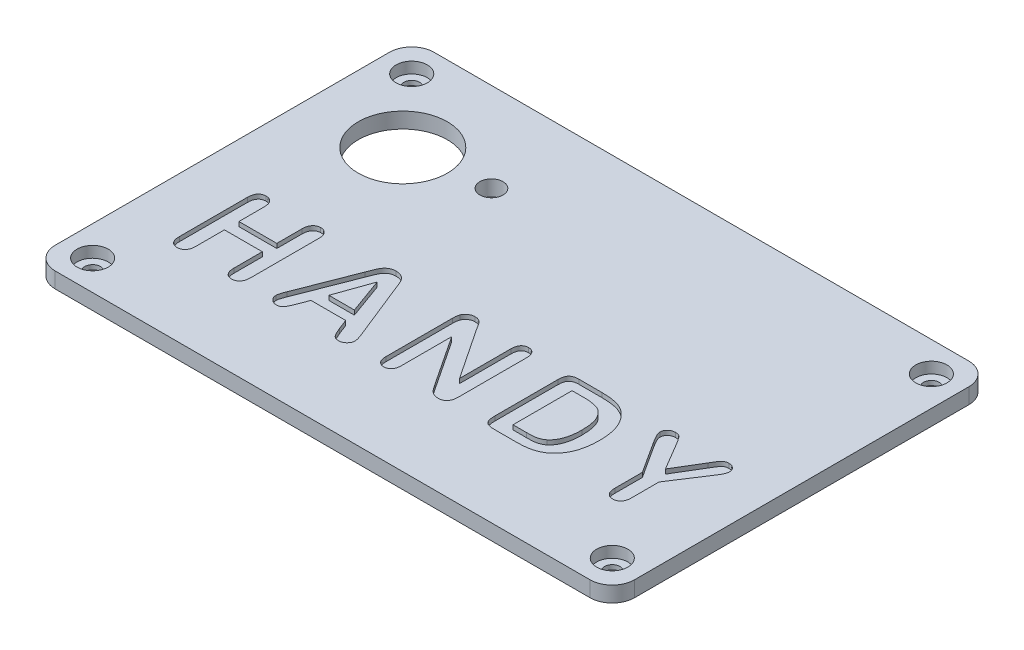
from build123d import *

# Parameters (mm, degrees)
SCHIZZO1_W                   = 130
SCHIZZO1_H                   = 85
ESTRUSIONE_ESTRUSIONE1_DEPTH = 3.5
RACCORDO1_R                  = 5
RACCORDO2_R                  = 5
RACCORDO3_R                  = 5
RACCORDO4_R                  = 5
SCHIZZO12_R                  = 10
TAGLIO_ESTRUSIONE2_DEPTH     = 3.5
SCHIZZO14_R                  = 2.6
TAGLIO_ESTRUSIONE3_DEPTH     = 3.5
TAGLIO_ESTRUSIONE9_DEPTH     = 1
SCHIZZO29_R                  = 1.75
TAGLIO_ESTRUSIONE10_DEPTH    = 3.5
SCHIZZO30_R                  = 3.5
TAGLIO_ESTRUSIONE11_DEPTH    = 2.5


with BuildPart() as part:
    # Schizzo1 → Estrusione-Estrusione1 (new body)
    with BuildSketch(Plane(origin=(0, 0, 0), x_dir=(1, 0, 0), z_dir=(0, 1, 0))):
        with Locations((65, 42.5)):
            Rectangle(SCHIZZO1_W, SCHIZZO1_H)
    extrude(amount=-ESTRUSIONE_ESTRUSIONE1_DEPTH)

    # Raccordo1
    raccordo1_edges = [part.edges().sort_by_distance(p)[0] for p in [
        (130, -1.75, 0),
    ]]
    fillet(raccordo1_edges, radius=RACCORDO1_R)

    # Raccordo2
    raccordo2_edges = [part.edges().sort_by_distance(p)[0] for p in [
        (130, -1.75, -85),
    ]]
    fillet(raccordo2_edges, radius=RACCORDO2_R)

    # Raccordo3
    raccordo3_edges = [part.edges().sort_by_distance(p)[0] for p in [
        (0, -1.75, -85),
    ]]
    fillet(raccordo3_edges, radius=RACCORDO3_R)

    # Raccordo4
    raccordo4_edges = [part.edges().sort_by_distance(p)[0] for p in [
        (0, -1.75, 0),
    ]]
    fillet(raccordo4_edges, radius=RACCORDO4_R)

    # Schizzo12 → Taglio-Estrusione2 (cut)
    with BuildSketch(Plane(origin=(0, 0, 0), x_dir=(1, 0, 0), z_dir=(0, 1, 0))):
        with Locations((20, 63)):
            Circle(SCHIZZO12_R)
    extrude(amount=-TAGLIO_ESTRUSIONE2_DEPTH, mode=Mode.SUBTRACT)

    # Schizzo14 → Taglio-Estrusione3 (cut)
    with BuildSketch(Plane(origin=(0, 0, 0), x_dir=(1, 0, 0), z_dir=(0, 1, 0))):
        with Locations((37.88854382, 65)):
            Circle(SCHIZZO14_R)
    extrude(amount=-TAGLIO_ESTRUSIONE3_DEPTH, mode=Mode.SUBTRACT)

    # Schizzo28 → Taglio-Estrusione9 (cut)
    with BuildSketch(Plane(origin=(0, 0, 0), x_dir=(1, 0, 0), z_dir=(0, 1, 0))):
        with BuildLine():
            Line((16, 35.829423521), (16, 30.227861021))
            Line((16, 30.227861021), (24.5, 30.227861021))
            Line((24.5, 30.227861021), (24.5, 35.829423521))
            add(Edge.make_bspline(
                [(24.5, 35.829423521), (24.504819175, 36.017416194), (24.513897939, 36.371572485), (24.611065343, 36.865238101), (24.769479801, 37.285985584), (24.994979646, 37.631146203), (25.278527591, 37.895342217), (25.599100815, 38.094603014), (25.967036773, 38.205160795), (26.223263113, 38.220134834), (26.35546875, 38.227861021)],
                knots=[0, 0, 0, 0, 0.000563367, 0.001061319, 0.001501635, 0.00190466, 0.002285995, 0.002655791, 0.003027707, 0.003424167, 0.003424167, 0.003424167, 0.003424167], degree=3))
            add(Edge.make_bspline(
                [(26.35546875, 38.227861021), (26.490542865, 38.222400532), (26.752884148, 38.211795157), (27.123820168, 38.091691153), (27.456477722, 37.906376855), (27.742311924, 37.641646055), (27.977193769, 37.303779609), (28.13964448, 36.885453798), (28.236139538, 36.393729531), (28.245182464, 36.040852835), (28.25, 35.852861021)],
                knots=[0, 0, 0, 0, 0.000403877, 0.00078441, 0.001157002, 0.001538537, 0.001942716, 0.002380843, 0.002874964, 0.003438332, 0.003438332, 0.003438332, 0.003438332], degree=3))
            Line((28.25, 35.852861021), (28.25, 20.614579771))
            add(Edge.make_bspline(
                [(28.25, 20.614579771), (28.245762205, 20.426462918), (28.237801584, 20.07308878), (28.133804062, 19.581462938), (27.973891929, 19.159089268), (27.735718866, 18.817428131), (27.444355306, 18.556757949), (27.118431825, 18.361575022), (26.747834988, 18.250386044), (26.489003393, 18.235526999), (26.35546875, 18.227861021)],
                knots=[0, 0, 0, 0, 0.000563367, 0.001058276, 0.001500027, 0.001909644, 0.002294067, 0.002665223, 0.003040873, 0.003441221, 0.003441221, 0.003441221, 0.003441221], degree=3))
            add(Edge.make_bspline(
                [(26.35546875, 18.227861021), (26.220311497, 18.233011963), (25.960302235, 18.242921106), (25.593818183, 18.365107708), (25.266599728, 18.548559267), (24.987209876, 18.813591642), (24.767299772, 19.154017113), (24.606190458, 19.564991003), (24.51530789, 20.04946092), (24.505314473, 20.395435279), (24.5, 20.579423521)],
                knots=[0, 0, 0, 0, 0.000403877, 0.000776959, 0.001146157, 0.00152197, 0.001919583, 0.002352631, 0.002838327, 0.003389994, 0.003389994, 0.003389994, 0.003389994], degree=3))
            Line((24.5, 20.579423521), (24.5, 26.977861021))
            Line((24.5, 26.977861021), (16, 26.977861021))
            Line((16, 26.977861021), (16, 20.579423521))
            add(Edge.make_bspline(
                [(16, 20.579423521), (15.995620095, 20.393939038), (15.987368634, 20.044498161), (15.884730284, 19.558859998), (15.722787066, 19.142357709), (15.485643023, 18.805492611), (15.194216223, 18.54836119), (14.867321444, 18.358589531), (14.498166265, 18.245306585), (14.239077497, 18.233796581), (14.10546875, 18.227861021)],
                knots=[0, 0, 0, 0, 0.000555567, 0.001046653, 0.001481161, 0.00188758, 0.002269394, 0.002638592, 0.003014242, 0.003414228, 0.003414228, 0.003414228, 0.003414228], degree=3))
            add(Edge.make_bspline(
                [(14.10546875, 18.227861021), (13.970525237, 18.23519005), (13.711427513, 18.249262122), (13.341980957, 18.363115869), (13.016489282, 18.553389644), (12.737201356, 18.821553811), (12.515263914, 19.167775393), (12.357906186, 19.586599094), (12.264714428, 20.077983215), (12.255118075, 20.42793701), (12.25, 20.614579771)],
                knots=[0, 0, 0, 0, 0.000404236, 0.000776151, 0.001147306, 0.00152581, 0.00192669, 0.002370647, 0.002860177, 0.003419644, 0.003419644, 0.003419644, 0.003419644], degree=3))
            Line((12.25, 20.614579771), (12.25, 35.852861021))
            add(Edge.make_bspline(
                [(12.25, 35.852861021), (12.254861535, 36.03961068), (12.263976876, 36.389764911), (12.359920335, 36.877721635), (12.505497685, 37.29786493), (12.731310913, 37.638071279), (13.006718206, 37.905942385), (13.335000733, 38.093312343), (13.705506461, 38.211940289), (13.969112261, 38.222433271), (14.10546875, 38.227861021)],
                knots=[0, 0, 0, 0, 0.000559467, 0.001048997, 0.001486532, 0.001884145, 0.002262648, 0.002628462, 0.003008996, 0.003416764, 0.003416764, 0.003416764, 0.003416764], degree=3))
            add(Edge.make_bspline(
                [(14.10546875, 38.227861021), (14.240555727, 38.222415396), (14.502921991, 38.211838891), (14.873680167, 38.091529357), (15.207775264, 37.906545548), (15.492282478, 37.637220489), (15.727229163, 37.29581373), (15.89021347, 36.872428327), (15.985724691, 36.375381758), (15.995051131, 36.018692698), (16, 35.829423521)],
                knots=[0, 0, 0, 0, 0.000403877, 0.00078441, 0.001157002, 0.001541187, 0.001948581, 0.002390333, 0.002892115, 0.003459383, 0.003459383, 0.003459383, 0.003459383], degree=3))
        make_face()
        with BuildLine():
            Line((48.11328125, 20.645829771), (47.19921875, 22.977861021))
            Line((47.19921875, 22.977861021), (39.421875, 22.977861021))
            Line((39.421875, 22.977861021), (38.5078125, 20.595048521))
            add(Edge.make_bspline(
                [(38.5078125, 20.595048521), (38.423880126, 20.380686838), (38.270045658, 19.987796539), (38.031609163, 19.460860576), (37.815483793, 19.045611246), (37.615071434, 18.723112851), (37.38130707, 18.485339378), (37.088182176, 18.333005971), (36.738340395, 18.24328834), (36.486278791, 18.233234418), (36.3515625, 18.227861021)],
                knots=[0, 0, 0, 0, 0.000690556, 0.001265678, 0.001733972, 0.002094745, 0.002401355, 0.002721214, 0.003072733, 0.003476289, 0.003476289, 0.003476289, 0.003476289], degree=3))
            add(Edge.make_bspline(
                [(36.3515625, 18.227861021), (36.232292304, 18.23458236), (35.997086222, 18.247837137), (35.657112775, 18.35543674), (35.339730265, 18.527029837), (35.051798307, 18.758969192), (34.808630848, 19.032860172), (34.632418345, 19.337365774), (34.519408043, 19.66016186), (34.506496599, 19.884508617), (34.5, 19.997392271)],
                knots=[0, 0, 0, 0, 0.000357203, 0.00070442, 0.001059201, 0.001434384, 0.0018081, 0.00215114, 0.002484661, 0.002822433, 0.002822433, 0.002822433, 0.002822433], degree=3))
            add(Edge.make_bspline(
                [(34.5, 19.997392271), (34.506021036, 20.132056724), (34.518389365, 20.408682609), (34.606367654, 20.757509051), (34.711996109, 21.059096915), (34.809592497, 21.332616659), (34.925514842, 21.648731366), (35.014979275, 21.871338033), (35.0625, 21.989579771)],
                knots=[0, 0, 0, 0, 0.000403556, 0.000828978, 0.001072329, 0.001362681, 0.001700092, 0.002082366, 0.002082366, 0.002082366, 0.002082366], degree=3))
            Line((35.0625, 21.989579771), (39.95703125, 34.548173521))
            add(Edge.make_bspline(
                [(39.95703125, 34.548173521), (39.993222724, 34.643329111), (40.068697286, 34.841768849), (40.192711767, 35.151331646), (40.318591306, 35.49025036), (40.457040416, 35.846035813), (40.597923576, 36.202370263), (40.75654517, 36.532490679), (40.909599004, 36.83556295), (41.075765981, 37.105428432), (41.256790067, 37.349102363), (41.464237199, 37.564323499), (41.699337666, 37.753177599), (41.956729117, 37.923893844), (42.24684487, 38.060834127), (42.568950603, 38.159011855), (42.922338043, 38.217641971), (43.169039081, 38.224373083), (43.296875, 38.227861021)],
                knots=[0, 0, 0, 0, 0.000305413, 0.000636915, 0.001000385, 0.001389935, 0.001782372, 0.002149331, 0.002488275, 0.002800482, 0.003098921, 0.003397283, 0.003694389, 0.004002091, 0.004321855, 0.004652989, 0.005009401, 0.005392712, 0.005392712, 0.005392712, 0.005392712], degree=3))
            add(Edge.make_bspline(
                [(43.296875, 38.227861021), (43.426028579, 38.224408528), (43.675347921, 38.217743802), (44.032358158, 38.158592175), (44.356896212, 38.062866669), (44.644448297, 37.922191818), (44.903689239, 37.756440943), (45.139591077, 37.570625171), (45.344786796, 37.355850612), (45.582491853, 37.040846266), (45.838224036, 36.613949879), (46.052176661, 36.153238269), (46.207312376, 35.747767817), (46.352416394, 35.400310434), (46.501661241, 35.001423448), (46.607989954, 34.720013053), (46.6640625, 34.571611021)],
                knots=[0, 0, 0, 0, 0.000387212, 0.000747477, 0.001082346, 0.001398583, 0.001704171, 0.002004317, 0.002297156, 0.002592485, 0.00318671, 0.003786112, 0.004113982, 0.004489002, 0.004915571, 0.005391509, 0.005391509, 0.005391509, 0.005391509], degree=3))
            Line((46.6640625, 34.571611021), (51.6640625, 22.095048521))
            add(Edge.make_bspline(
                [(51.6640625, 22.095048521), (51.709769372, 21.980533321), (51.797785114, 21.760016364), (51.922269913, 21.441666952), (52.01508165, 21.143075814), (52.107401459, 20.873893132), (52.166344257, 20.624468819), (52.215273245, 20.402385557), (52.245511947, 20.203967891), (52.248561909, 20.079512074), (52.25, 20.020829771)],
                knots=[0, 0, 0, 0, 0.000369941, 0.000712379, 0.001024903, 0.001307803, 0.001565497, 0.001793034, 0.001990251, 0.002166206, 0.002166206, 0.002166206, 0.002166206], degree=3))
            add(Edge.make_bspline(
                [(52.25, 20.020829771), (52.242816192, 19.910753739), (52.228398423, 19.689833194), (52.122771788, 19.365634001), (51.939387808, 19.06224382), (51.701786429, 18.777764097), (51.415890172, 18.53381929), (51.088694902, 18.35653975), (50.733475439, 18.247272147), (50.485143947, 18.234386853), (50.359375, 18.227861021)],
                knots=[0, 0, 0, 0, 0.000330003, 0.00066231, 0.00101069, 0.0013878, 0.001770413, 0.002130488, 0.00249753, 0.002874174, 0.002874174, 0.002874174, 0.002874174], degree=3))
            add(Edge.make_bspline(
                [(50.359375, 18.227861021), (50.216513945, 18.234138302), (49.947354439, 18.245965107), (49.575155849, 18.366061202), (49.270144054, 18.562281574), (49.054536567, 18.772119195), (48.906206737, 18.981387813), (48.789505095, 19.173618751), (48.668920788, 19.400859535), (48.508341352, 19.740780654), (48.3275959, 20.161800825), (48.181258205, 20.492304037), (48.11328125, 20.645829771)],
                knots=[0, 0, 0, 0, 0.000427569, 0.000805568, 0.001156697, 0.001507499, 0.001700493, 0.001924924, 0.002181817, 0.002471855, 0.003052508, 0.003556217, 0.003556217, 0.003556217, 0.003556217], degree=3))
        make_face()
        Polygon((40.4375, 25.977861021), (46.15625, 25.977861021), (43.26953125, 33.977861021), align=None, mode=Mode.SUBTRACT)
        with BuildLine():
            Line((63.6484375, 35.880204771), (71.25, 24.477861021))
            Line((71.25, 24.477861021), (71.25, 35.985673521))
            add(Edge.make_bspline(
                [(71.25, 35.985673521), (71.255868356, 36.161820292), (71.266860048, 36.491751043), (71.35036402, 36.95434511), (71.496680678, 37.346754937), (71.704021914, 37.669002302), (71.961809857, 37.921041713), (72.266190227, 38.100092989), (72.611176317, 38.209821126), (72.854638509, 38.221714227), (72.98046875, 38.227861021)],
                knots=[0, 0, 0, 0, 0.000528269, 0.000989471, 0.001403699, 0.001776414, 0.00213001, 0.002475023, 0.002827128, 0.003203772, 0.003203772, 0.003203772, 0.003203772], degree=3))
            add(Edge.make_bspline(
                [(72.98046875, 38.227861021), (73.110127528, 38.221598805), (73.361093779, 38.209477722), (73.716006385, 38.101983152), (74.026201235, 37.921073432), (74.288068543, 37.669372162), (74.499189408, 37.34711374), (74.650643821, 36.955183632), (74.732806637, 36.49163752), (74.744015629, 36.161780779), (74.75, 35.985673521)],
                knots=[0, 0, 0, 0, 0.000388313, 0.000751616, 0.001099995, 0.001456407, 0.001831265, 0.002246909, 0.002708111, 0.00323638, 0.00323638, 0.00323638, 0.00323638], degree=3))
            Line((74.75, 35.985673521), (74.75, 20.774736021))
            add(Edge.make_bspline(
                [(74.75, 20.774736021), (74.745174491, 20.575073674), (74.736117569, 20.200330559), (74.639626288, 19.676341561), (74.476900564, 19.230329998), (74.249222554, 18.86027055), (73.949565181, 18.569937355), (73.579114292, 18.370377167), (73.147194842, 18.245738042), (72.838158207, 18.234018705), (72.67578125, 18.227861021)],
                knots=[0, 0, 0, 0, 0.000598473, 0.001123264, 0.001590514, 0.002015345, 0.00241594, 0.00282684, 0.00326575, 0.003751698, 0.003751698, 0.003751698, 0.003751698], degree=3))
            add(Edge.make_bspline(
                [(72.67578125, 18.227861021), (72.511156346, 18.235585178), (72.193638966, 18.250483011), (71.736222214, 18.359250502), (71.320328346, 18.56216789), (70.946639622, 18.85557386), (70.596807597, 19.211425687), (70.276592022, 19.624180118), (69.974903176, 20.07136259), (69.768421718, 20.37252397), (69.6640625, 20.524736021)],
                knots=[0, 0, 0, 0, 0.000493735, 0.000952283, 0.001399527, 0.001870631, 0.002370586, 0.002893411, 0.003435198, 0.003988853, 0.003988853, 0.003988853, 0.003988853], degree=3))
            Line((69.6640625, 20.524736021), (62.25, 31.727861021))
            Line((62.25, 31.727861021), (62.25, 20.458329771))
            add(Edge.make_bspline(
                [(62.25, 20.458329771), (62.24414523, 20.286105851), (62.233054804, 19.959869905), (62.147420964, 19.501126027), (61.989885664, 19.109435025), (61.773443875, 18.787323016), (61.507653017, 18.53669841), (61.203796651, 18.356266351), (60.86282235, 18.246227756), (60.623222048, 18.234098748), (60.5, 18.227861021)],
                knots=[0, 0, 0, 0, 0.000516571, 0.000978517, 0.00139199, 0.001774443, 0.002133691, 0.002478704, 0.002827083, 0.00319595, 0.00319595, 0.00319595, 0.00319595], degree=3))
            add(Edge.make_bspline(
                [(60.5, 18.227861021), (60.374159566, 18.233865286), (60.129038474, 18.245560829), (59.782066186, 18.358600869), (59.476899846, 18.545152971), (59.210401737, 18.797192468), (59.00304093, 19.125380235), (58.854932262, 19.517089598), (58.765975986, 19.972633473), (58.755534077, 20.297744083), (58.75, 20.470048521)],
                knots=[0, 0, 0, 0, 0.000376644, 0.000733655, 0.001080674, 0.001442609, 0.001824004, 0.002234588, 0.002692703, 0.003209274, 0.003209274, 0.003209274, 0.003209274], degree=3))
            Line((58.75, 20.470048521), (58.75, 35.391923521))
            add(Edge.make_bspline(
                [(58.75, 35.391923521), (58.751465503, 35.541805554), (58.754236631, 35.825218363), (58.795223995, 36.224283087), (58.851233184, 36.575498219), (58.920663161, 36.785789688), (58.953125, 36.884111021)],
                knots=[0, 0, 0, 0, 0.000449372, 0.000849719, 0.001202949, 0.001513121, 0.001513121, 0.001513121, 0.001513121], degree=3))
            add(Edge.make_bspline(
                [(58.953125, 36.884111021), (58.996684545, 36.979781875), (59.083648749, 37.170783408), (59.27434086, 37.42386785), (59.491988341, 37.65974312), (59.75465064, 37.85406866), (60.038056324, 38.019225896), (60.338623416, 38.141291027), (60.652759254, 38.214568299), (60.865504998, 38.22340855), (60.97265625, 38.227861021)],
                knots=[0, 0, 0, 0, 0.000314447, 0.000627776, 0.00094553, 0.001274444, 0.001603429, 0.001927671, 0.002244173, 0.002565342, 0.002565342, 0.002565342, 0.002565342], degree=3))
            add(Edge.make_bspline(
                [(60.97265625, 38.227861021), (61.132771366, 38.221490933), (61.433016453, 38.209545855), (61.847017276, 38.071269854), (62.19945443, 37.868569592), (62.504226542, 37.591891294), (62.79239652, 37.24995298), (63.059477427, 36.828396208), (63.348694842, 36.365280182), (63.546999232, 36.044362951), (63.6484375, 35.880204771)],
                knots=[0, 0, 0, 0, 0.000478496, 0.000897267, 0.001294573, 0.00169034, 0.002125479, 0.00263251, 0.003185282, 0.003764146, 0.003764146, 0.003764146, 0.003764146], degree=3))
        make_face()
        with BuildLine():
            Line((84.796875, 37.727861021), (89.92578125, 37.727861021))
            add(Edge.make_bspline(
                [(89.92578125, 37.727861021), (90.247497016, 37.723258254), (90.868216219, 37.714377664), (91.763340794, 37.649761444), (92.58632338, 37.536035895), (93.347789668, 37.383997193), (94.058334511, 37.162594848), (94.731118893, 36.869184793), (95.37005613, 36.492149665), (95.7598414, 36.184354072), (95.95703125, 36.028642271)],
                knots=[0, 0, 0, 0, 0.000965128, 0.001862121, 0.002690218, 0.003456322, 0.00418896, 0.004918352, 0.005653931, 0.006407058, 0.006407058, 0.006407058, 0.006407058], degree=3))
            add(Edge.make_bspline(
                [(95.95703125, 36.028642271), (96.080681857, 35.918002986), (96.327868753, 35.696826706), (96.675088486, 35.341984114), (96.9973639, 34.964777075), (97.293601363, 34.565904467), (97.567605814, 34.147216817), (97.818445631, 33.707861595), (98.046502233, 33.246983125), (98.242431477, 32.760597865), (98.425271894, 32.257903771), (98.574124419, 31.731914864), (98.710752943, 31.188498513), (98.812326138, 30.620154274), (98.900677151, 30.033112796), (98.95725437, 29.424066984), (98.993659407, 28.794720158), (98.997861824, 28.367237714), (99, 28.149736021)],
                knots=[0, 0, 0, 0, 0.000497675, 0.00099489, 0.001488069, 0.001984946, 0.002484412, 0.002988303, 0.003501912, 0.004025655, 0.004560641, 0.005105797, 0.005664773, 0.006240915, 0.006836986, 0.007445284, 0.008075172, 0.008727621, 0.008727621, 0.008727621, 0.008727621], degree=3))
            add(Edge.make_bspline(
                [(99, 28.149736021), (98.995982851, 27.864507149), (98.988142691, 27.307833763), (98.934683677, 26.489939728), (98.836291009, 25.711819689), (98.704614169, 24.969281968), (98.533645136, 24.263944181), (98.319717055, 23.594903247), (98.060205089, 22.961795415), (97.759006649, 22.36421045), (97.418764314, 21.79633251), (97.02801725, 21.265141356), (96.600470059, 20.756388453), (96.279002638, 20.448997048), (96.1171875, 20.294267271)],
                knots=[0, 0, 0, 0, 0.000855692, 0.00167003, 0.00245736, 0.003207492, 0.003931319, 0.004632989, 0.005312688, 0.005981763, 0.006638954, 0.007296052, 0.007958286, 0.00862949, 0.00862949, 0.00862949, 0.00862949], degree=3))
            add(Edge.make_bspline(
                [(96.1171875, 20.294267271), (95.986027745, 20.185340228), (95.725881866, 19.969291324), (95.307652468, 19.684239696), (94.874337747, 19.428376151), (94.419694539, 19.210647327), (93.949217173, 19.023546867), (93.463437239, 18.861507718), (92.959351538, 18.733531341), (92.4360054, 18.635601554), (91.88789828, 18.566919262), (91.309355697, 18.516517653), (90.695656647, 18.484997663), (90.274777707, 18.480282803), (90.05859375, 18.477861021)],
                knots=[0, 0, 0, 0, 0.000511227, 0.001013981, 0.001516447, 0.00201961, 0.00252447, 0.003034635, 0.003554768, 0.004083398, 0.004630901, 0.005211252, 0.005825329, 0.006473872, 0.006473872, 0.006473872, 0.006473872], degree=3))
            Line((90.05859375, 18.477861021), (84.97265625, 18.477861021))
            add(Edge.make_bspline(
                [(84.97265625, 18.477861021), (84.805688962, 18.480444198), (84.492544733, 18.485288901), (84.055827412, 18.5505011), (83.680575439, 18.640567517), (83.369560843, 18.784439963), (83.118936386, 18.96802086), (82.915138498, 19.181759325), (82.759662129, 19.428752369), (82.65323241, 19.712304732), (82.588516838, 20.031849693), (82.537087337, 20.390529104), (82.50690139, 20.792466214), (82.502374945, 21.075468541), (82.5, 21.223954771)],
                knots=[0, 0, 0, 0, 0.000500381, 0.000938456, 0.001322185, 0.001654216, 0.001958928, 0.002249071, 0.002535189, 0.002828262, 0.003152386, 0.003511464, 0.00391502, 0.004360486, 0.004360486, 0.004360486, 0.004360486], degree=3))
            Line((82.5, 21.223954771), (82.5, 35.337236021))
            add(Edge.make_bspline(
                [(82.5, 35.337236021), (82.505972839, 35.53308572), (82.517137247, 35.899167276), (82.617602527, 36.406411412), (82.780985233, 36.83272017), (83.028213168, 37.173751189), (83.358160207, 37.429241261), (83.766545626, 37.608194722), (84.256726485, 37.711068843), (84.608853431, 37.722015792), (84.796875, 37.727861021)],
                knots=[0, 0, 0, 0, 0.000586991, 0.001097202, 0.001544037, 0.001946399, 0.002344166, 0.002781247, 0.003273156, 0.003836753, 0.003836753, 0.003836753, 0.003836753], degree=3))
        make_face()
        with BuildLine():
            Line((86.25, 34.727861021), (86.25, 21.477861021))
            Line((86.25, 21.477861021), (89.25390625, 21.477861021))
            add(Edge.make_bspline(
                [(89.25390625, 21.477861021), (89.410156803, 21.478919952), (89.704448449, 21.480914406), (90.119933718, 21.487383672), (90.48076458, 21.502506798), (90.896860426, 21.531924816), (91.39212726, 21.613094508), (91.876235699, 21.75353156), (92.258421949, 21.906480067), (92.529720191, 22.045385795), (92.781147753, 22.20777987), (92.9321688, 22.333072812), (93.0078125, 22.395829771)],
                knots=[0, 0, 0, 0, 0.000468766, 0.000882902, 0.00124652, 0.001552107, 0.002133929, 0.002748304, 0.003060217, 0.003367696, 0.003661315, 0.003955972, 0.003955972, 0.003955972, 0.003955972], degree=3))
            add(Edge.make_bspline(
                [(93.0078125, 22.395829771), (93.169395684, 22.543233536), (93.49622798, 22.841385298), (93.895698296, 23.389732369), (94.241989415, 24.002471913), (94.524142651, 24.69268333), (94.734481242, 25.459381946), (94.889835272, 26.298188406), (94.983812409, 27.212711848), (94.99446646, 27.847421774), (95, 28.177079771)],
                knots=[0, 0, 0, 0, 0.000654679, 0.00132421, 0.002023855, 0.002763045, 0.003554482, 0.004404897, 0.005319869, 0.006308644, 0.006308644, 0.006308644, 0.006308644], degree=3))
            add(Edge.make_bspline(
                [(95, 28.177079771), (94.998712682, 28.410249081), (94.996214739, 28.862696665), (94.949642217, 29.517946887), (94.888394691, 30.129094662), (94.787506638, 30.692898958), (94.671452981, 31.214304704), (94.516854387, 31.687098616), (94.343732318, 32.118499256), (94.134025519, 32.501593824), (93.906608519, 32.845830433), (93.667444555, 33.156482218), (93.416798625, 33.434698802), (93.155608538, 33.683832407), (92.876185162, 33.894689974), (92.586057924, 34.075225476), (92.283935414, 34.22710086), (91.851690521, 34.375743448), (91.273969246, 34.517312095), (90.531230046, 34.64284611), (89.721538749, 34.716379019), (89.159008112, 34.723939115), (88.8671875, 34.727861021)],
                knots=[0, 0, 0, 0, 0.000699317, 0.001356972, 0.001969955, 0.002540869, 0.003074326, 0.003570927, 0.004031566, 0.004466776, 0.004878473, 0.005268355, 0.005641745, 0.006000992, 0.006349438, 0.006689797, 0.007025212, 0.007361286, 0.008058582, 0.00880737, 0.009619363, 0.010494677, 0.010494677, 0.010494677, 0.010494677], degree=3))
            Line((88.8671875, 34.727861021), (86.25, 34.727861021))
        make_face(mode=Mode.SUBTRACT)
        with BuildLine():
            Line((110, 20.614579771), (110, 26.751298521))
            Line((110, 26.751298521), (105.27734375, 34.071611021))
            add(Edge.make_bspline(
                [(105.27734375, 34.071611021), (105.18208343, 34.227727129), (105.004124088, 34.519373432), (104.758200932, 34.929361303), (104.563935093, 35.289032699), (104.406222903, 35.598482658), (104.287510458, 35.872837566), (104.211330371, 36.125050073), (104.153473354, 36.356776865), (104.147419932, 36.507499125), (104.14453125, 36.579423521)],
                knots=[0, 0, 0, 0, 0.000548672, 0.001024994, 0.001434014, 0.001774665, 0.002067034, 0.002328957, 0.002564954, 0.002780365, 0.002780365, 0.002780365, 0.002780365], degree=3))
            add(Edge.make_bspline(
                [(104.14453125, 36.579423521), (104.149917651, 36.688308267), (104.160533619, 36.902907412), (104.264883975, 37.212093442), (104.431089348, 37.496456359), (104.65995968, 37.749132418), (104.933002638, 37.963565636), (105.247125235, 38.117574986), (105.591093961, 38.210536048), (105.830137306, 38.221975452), (105.953125, 38.227861021)],
                knots=[0, 0, 0, 0, 0.000325721, 0.000641959, 0.000967563, 0.001307855, 0.001658679, 0.002002828, 0.002350572, 0.002719087, 0.002719087, 0.002719087, 0.002719087], degree=3))
            add(Edge.make_bspline(
                [(105.953125, 38.227861021), (106.078708193, 38.223588972), (106.317582144, 38.215463036), (106.652943053, 38.127943092), (106.94309966, 37.983672969), (107.140890723, 37.804254792), (107.285084873, 37.629675713), (107.409374083, 37.471083727), (107.545047979, 37.281808489), (107.698361967, 37.069386826), (107.857953647, 36.823665733), (108.03346401, 36.552186526), (108.221337062, 36.249481604), (108.350411587, 36.037848047), (108.41796875, 35.927079771)],
                knots=[0, 0, 0, 0, 0.000375996, 0.000715188, 0.001031401, 0.001338607, 0.001507662, 0.001710825, 0.001942877, 0.002206252, 0.002496605, 0.00282167, 0.003176107, 0.003565343, 0.003565343, 0.003565343, 0.003565343], degree=3))
            Line((108.41796875, 35.927079771), (111.9453125, 29.977861021))
            Line((111.9453125, 29.977861021), (115.515625, 35.927079771))
            add(Edge.make_bspline(
                [(115.515625, 35.927079771), (115.617280023, 36.096295101), (115.8019613, 36.403716243), (116.059568981, 36.835439149), (116.299249878, 37.213519148), (116.551252561, 37.553593158), (116.835201203, 37.843872414), (117.160041432, 38.06833652), (117.543785327, 38.209443035), (117.821613096, 38.221484101), (117.96875, 38.227861021)],
                knots=[0, 0, 0, 0, 0.000592206, 0.001075888, 0.001508213, 0.001934781, 0.002343578, 0.002720607, 0.003111075, 0.00355068, 0.00355068, 0.00355068, 0.00355068], degree=3))
            add(Edge.make_bspline(
                [(117.96875, 38.227861021), (118.087869598, 38.222087612), (118.318041836, 38.210931779), (118.648008102, 38.117516156), (118.945703027, 37.963027523), (119.203982023, 37.750513199), (119.423468996, 37.506598397), (119.57697872, 37.230682088), (119.678890821, 36.938017721), (119.689779141, 36.733923741), (119.6953125, 36.630204771)],
                knots=[0, 0, 0, 0, 0.00035684, 0.000689514, 0.001019725, 0.001355867, 0.001688059, 0.001997664, 0.002297836, 0.002608008, 0.002608008, 0.002608008, 0.002608008], degree=3))
            add(Edge.make_bspline(
                [(119.6953125, 36.630204771), (119.692369316, 36.54404104), (119.686483958, 36.371743145), (119.636183657, 36.113706534), (119.558364015, 35.85558135), (119.443885697, 35.589396168), (119.287567328, 35.301857316), (119.095717799, 34.969957102), (118.862154061, 34.58688236), (118.684592063, 34.319667481), (118.58984375, 34.177079771)],
                knots=[0, 0, 0, 0, 0.000258286, 0.000516482, 0.000785872, 0.001065926, 0.001383944, 0.001767194, 0.002216056, 0.002729606, 0.002729606, 0.002729606, 0.002729606], degree=3))
            Line((118.58984375, 34.177079771), (113.75, 26.751298521))
            Line((113.75, 26.751298521), (113.75, 20.614579771))
            add(Edge.make_bspline(
                [(113.75, 20.614579771), (113.745761231, 20.426464602), (113.73779878, 20.073093628), (113.633813281, 19.581446999), (113.473862283, 19.159140525), (113.235818381, 18.817256074), (112.94485626, 18.558099989), (112.621658487, 18.360535335), (112.254146345, 18.251363917), (111.99805422, 18.235809533), (111.8671875, 18.227861021)],
                knots=[0, 0, 0, 0, 0.000563367, 0.001058276, 0.001500027, 0.001909644, 0.002294067, 0.002661857, 0.003037507, 0.003430081, 0.003430081, 0.003430081, 0.003430081], degree=3))
            add(Edge.make_bspline(
                [(111.8671875, 18.227861021), (111.734719413, 18.233421654), (111.476233885, 18.24427214), (111.112146953, 18.363689741), (110.783621314, 18.547435478), (110.499936896, 18.809218163), (110.266724673, 19.150328526), (110.11242338, 19.574244711), (110.013307568, 20.069631173), (110.004624206, 20.425217269), (110, 20.614579771)],
                knots=[0, 0, 0, 0, 0.000396095, 0.000772901, 0.00113677, 0.001518305, 0.001920269, 0.002364226, 0.002862177, 0.003429445, 0.003429445, 0.003429445, 0.003429445], degree=3))
        make_face()
    extrude(amount=-TAGLIO_ESTRUSIONE9_DEPTH, mode=Mode.SUBTRACT)

    # Schizzo29 → Taglio-Estrusione10 (cut)
    with BuildSketch(Plane(origin=(0, 0, 0), x_dir=(1, 0, 0), z_dir=(0, 1, 0))):
        with Locations((6.7, 78.3)):
            Circle(SCHIZZO29_R)
        with Locations((6.7, 6.7)):
            Circle(SCHIZZO29_R)
        with Locations((123.3, 6.7)):
            Circle(SCHIZZO29_R)
        with Locations((123.3, 78.3)):
            Circle(SCHIZZO29_R)
    extrude(amount=-TAGLIO_ESTRUSIONE10_DEPTH, mode=Mode.SUBTRACT)

    # Schizzo30 → Taglio-Estrusione11 (cut)
    with BuildSketch(Plane(origin=(0, 0, 0), x_dir=(1, 0, 0), z_dir=(0, 1, 0))):
        with Locations((6.7, 78.3)):
            Circle(SCHIZZO30_R)
        with Locations((6.7, 6.7)):
            Circle(SCHIZZO30_R)
        with Locations((123.3, 6.7)):
            Circle(SCHIZZO30_R)
        with Locations((123.3, 78.3)):
            Circle(SCHIZZO30_R)
    extrude(amount=-TAGLIO_ESTRUSIONE11_DEPTH, mode=Mode.SUBTRACT)


solid = part.part
